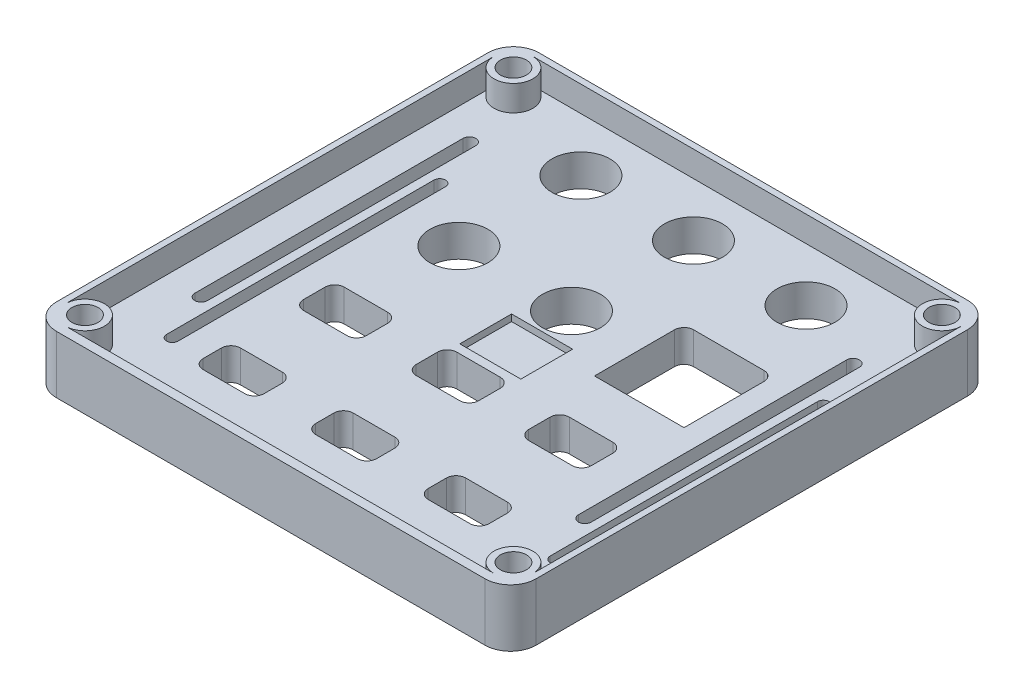
from build123d import *

# Parameters (mm, degrees)
SKETCH1_W                   = 150
SKETCH1_H                   = 150.9
BOSS_EXTRUDE1_DEPTH         = 10
SKETCH2_R                   = 9.075
SKETCH2_W                   = 19.6
SKETCH2_H                   = 12.7
SKETCH2_W_2                 = 19.05
SKETCH2_H_2                 = 11.7
SKETCH2_W_3                 = 28
SKETCH2_H_3                 = 28
CUT_EXTRUDE1_DEPTH          = 10
FILLET1_R                   = 8
FILLET2_R                   = 3
SKETCH5_R                   = 4.075
CUT_EXTRUDE4_DEPTH          = 10
MIRROR3_COPY_1_SKETCH_R     = 4.075
MIRROR3_COPY_1_DEPTH        = 10
FILLET6_R                   = 3
CUT_EXTRUDE6_DEPTH          = 11
LPATTERN3_COUNT             = 2
LPATTERN3_PITCH             = 120
SKETCH9_R                   = 6.075
SKETCH9_R_2                 = 4.075
BOSS_EXTRUDE2_DEPTH         = 8
LPATTERN4_COUNT             = 2
LPATTERN4_PITCH             = 134
LPATTERN5_COUNT             = 2
LPATTERN5_PITCH             = 134
LPATTERN5_COPY_1_SKETCH_R   = 6.075
LPATTERN5_COPY_1_SKETCH_R_2 = 4.075
LPATTERN5_COPY_1_DEPTH      = 8
BOSS_EXTRUDE4_DEPTH         = 8
SKETCH12_W                  = 19.1
SKETCH12_H                  = 16.2
CUT_EXTRUDE7_DEPTH          = 2.07


with BuildPart() as part:
    # Sketch1 → Boss-Extrude1 (new body)
    with BuildSketch(Plane(origin=(0, 0, 0), x_dir=(1, 0, 0), z_dir=(0, 1, 0))):
        Rectangle(SKETCH1_W, SKETCH1_H)
    extrude(amount=BOSS_EXTRUDE1_DEPTH)

    # Sketch2 → Cut-Extrude1 (cut)
    with BuildSketch(Plane(origin=(0, 10, 0), x_dir=(1, 0, 0), z_dir=(0, 1, 0))):
        with Locations((-35.2, 56.75)):
            Circle(SKETCH2_R)
        with Locations((0, 56.75)):
            Circle(SKETCH2_R)
        with Locations((35.2, 56.75)):
            Circle(SKETCH2_R)
        with Locations((-35.2, 18.6)):
            Circle(SKETCH2_R)
        with Locations((0, 18.6)):
            Circle(SKETCH2_R)
        with Locations((0, -16.825)):
            Rectangle(SKETCH2_W, SKETCH2_H)
        with Locations((-35.2, -16.825)):
            Rectangle(SKETCH2_W, SKETCH2_H)
        with Locations((35.2, -16.825)):
            Rectangle(SKETCH2_W, SKETCH2_H)
        with Locations((-35.2, -49.025)):
            Rectangle(SKETCH2_W_2, SKETCH2_H_2)
        with Locations((0, -49.025)):
            Rectangle(SKETCH2_W_2, SKETCH2_H_2)
        with Locations((35.2, -49.025)):
            Rectangle(SKETCH2_W_2, SKETCH2_H_2)
        with Locations((35.2, 18.6)):
            Rectangle(SKETCH2_W_3, SKETCH2_H_3)
    extrude(amount=-CUT_EXTRUDE1_DEPTH, mode=Mode.SUBTRACT)

    # Fillet1
    fillet1_edges = [part.edges().sort_by_distance(p)[0] for p in [
        (75, 5, 75.45),
        (-75, 5, 75.45),
        (-75, 5, -75.45),
        (75, 5, -75.45),
    ]]
    fillet(fillet1_edges, radius=FILLET1_R)

    # Fillet2
    fillet2_edges = [part.edges().sort_by_distance(p)[0] for p in [
        (25.4, 5, 23.175),
        (25.4, 5, 10.475),
        (45, 5, 10.475),
        (45, 5, 23.175),
        (-44.725, 5, 54.875),
        (-44.725, 5, 43.175),
        (-25.675, 5, 43.175),
        (-25.675, 5, 54.875),
        (-9.525, 5, 54.875),
        (-9.525, 5, 43.175),
        (9.525, 5, 43.175),
        (9.525, 5, 54.875),
        (25.675, 5, 54.875),
        (25.675, 5, 43.175),
        (44.725, 5, 43.175),
        (44.725, 5, 54.875),
        (-9.8, 5, 23.175),
        (-9.8, 5, 10.475),
        (9.8, 5, 10.475),
        (9.8, 5, 23.175),
        (-45, 5, 23.175),
        (-45, 5, 10.475),
        (-25.4, 5, 10.475),
        (-25.4, 5, 23.175),
    ]]
    fillet(fillet2_edges, radius=FILLET2_R)

    # Sketch5 → Cut-Extrude4 (cut)
    with BuildSketch(Plane(origin=(0, 10, 0), x_dir=(1, 0, 0), z_dir=(0, 1, 0))):
        with Locations((-67, 67.45)):
            Circle(SKETCH5_R)
    cut_extrude4 = extrude(amount=-CUT_EXTRUDE4_DEPTH, mode=Mode.SUBTRACT)

    # Mirror1: Cut-Extrude4 across plane
    add(cut_extrude4.mirror(Plane.XY), mode=Mode.SUBTRACT)

    # Mirror3: Cut-Extrude4 across plane
    add(cut_extrude4.mirror(Plane(origin=(0, 0, 0), x_dir=(0, 0, 1), z_dir=(1, 0, 0))), mode=Mode.SUBTRACT)

    # Mirror3 copy 1 sketch → Mirror3 copy 1 (cut)
    with BuildSketch(Plane(origin=(0, 10, 0), x_dir=(-1, 0, 0), z_dir=(0, 1, 0))):
        with Locations((-67, 67.45)):
            Circle(MIRROR3_COPY_1_SKETCH_R)
    extrude(amount=-MIRROR3_COPY_1_DEPTH, mode=Mode.SUBTRACT)

    # Fillet6
    fillet6_edges = [part.edges().sort_by_distance(p)[0] for p in [
        (21.2, 5, -32.6),
        (49.2, 5, -32.6),
    ]]
    fillet(fillet6_edges, radius=FILLET6_R)

    # Sketch7 → Cut-Extrude6 (cut, through all)
    with BuildSketch(Plane(origin=(0, 10, 0), x_dir=(1, 0, 0), z_dir=(0, 1, 0))):
        with BuildLine():
            Line((60.272487235, 48.384614922), (60.272487235, -35.499184585))
            ThreePointArc((60.272487235, -35.499184585), (58.278399823, -37.493271997), (56.284312411, -35.499184585))
            Line((56.284312411, -35.499184585), (56.284312411, 48.384614922))
            ThreePointArc((56.284312411, 48.384614922), (58.278399823, 50.378702334), (60.272487235, 48.384614922))
        make_face()
        with BuildLine():
            Line((66.651655516, 32.551344452), (66.651655516, -51.076821304))
            ThreePointArc((66.651655516, -51.076821304), (64.83996028, -52.88851654), (63.028265044, -51.076821304))
            Line((63.028265044, -51.076821304), (63.028265044, 32.551344452))
            ThreePointArc((63.028265044, 32.551344452), (64.83996028, 34.363039688), (66.651655516, 32.551344452))
        make_face()
    cut_extrude6 = extrude(amount=-CUT_EXTRUDE6_DEPTH, mode=Mode.SUBTRACT)

    # LPattern3: Cut-Extrude6 ×2
    with Locations(*[(-i * LPATTERN3_PITCH, 0, 0) for i in range(1, LPATTERN3_COUNT)]):
        add(cut_extrude6, mode=Mode.SUBTRACT)

    # Sketch9 → Boss-Extrude2 (add)
    with BuildSketch(Plane(origin=(0, 10, 0), x_dir=(1, 0, 0), z_dir=(0, 1, 0))):
        with Locations((-67, 67.45)):
            Circle(SKETCH9_R)
        with Locations((-67, 67.45)):
            Circle(SKETCH9_R_2, mode=Mode.SUBTRACT)
    boss_extrude2 = extrude(amount=BOSS_EXTRUDE2_DEPTH)

    # LPattern4: Boss-Extrude2 ×2
    with Locations(*[(i * LPATTERN4_PITCH, 0, 0) for i in range(1, LPATTERN4_COUNT)]):
        add(boss_extrude2)

    # LPattern5: Boss-Extrude2 ×2
    with Locations(*[(0, 0, i * LPATTERN5_PITCH) for i in range(1, LPATTERN5_COUNT)]):
        add(boss_extrude2)

    # LPattern5 copy 1 sketch → LPattern5 copy 1 (add)
    with BuildSketch(Plane(origin=(134, 10, 134), x_dir=(1, 0, 0), z_dir=(0, 1, 0))):
        with Locations((-67, 67.45)):
            Circle(LPATTERN5_COPY_1_SKETCH_R)
        with Locations((-67, 67.45)):
            Circle(LPATTERN5_COPY_1_SKETCH_R_2, mode=Mode.SUBTRACT)
    extrude(amount=LPATTERN5_COPY_1_DEPTH)

    # Sketch10 → Boss-Extrude4 (add)
    with BuildSketch(Plane(origin=(0, 10, 0), x_dir=(1, 0, 0), z_dir=(0, 1, 0))):
        with BuildLine():
            Line((-67, 75.45), (67, 75.45))
            ThreePointArc((67, 75.45), (72.656854249, 73.106854249), (75, 67.45))
            Line((75, 67.45), (75, -67.45))
            ThreePointArc((75, -67.45), (72.656854249, -73.106854249), (67, -75.45))
            Line((67, -75.45), (-67, -75.45))
            ThreePointArc((-67, -75.45), (-72.656854249, -73.106854249), (-75, -67.45))
            Line((-75, -67.45), (-75, 67.45))
            ThreePointArc((-75, 67.45), (-72.656854249, 73.106854249), (-67, 75.45))
        make_face()
        with BuildLine():
            Line((-67, 73.525), (67, 73.525))
            ThreePointArc((67, 73.525), (71.295673696, 71.745673696), (73.075, 67.45))
            Line((73.075, 67.45), (73.075, -66.55))
            ThreePointArc((73.075, -66.55), (71.295673696, -70.845673696), (67, -72.625))
            Line((67, -72.625), (-67, -72.625))
            ThreePointArc((-67, -72.625), (-71.295673696, -70.845673696), (-73.075, -66.55))
            Line((-73.075, -66.55), (-73.075, 67.45))
            ThreePointArc((-73.075, 67.45), (-71.295673696, 71.745673696), (-67, 73.525))
        make_face(mode=Mode.SUBTRACT)
    extrude(amount=BOSS_EXTRUDE4_DEPTH)

    # Sketch12 → Cut-Extrude7 (cut)
    with BuildSketch(Plane(origin=(0, 10, 0), x_dir=(1, 0, 0), z_dir=(0, 1, 0))):
        with Locations((0.98628476, 0.329027808)):
            Rectangle(SKETCH12_W, SKETCH12_H)
    extrude(amount=-CUT_EXTRUDE7_DEPTH, mode=Mode.SUBTRACT)


solid = part.part
